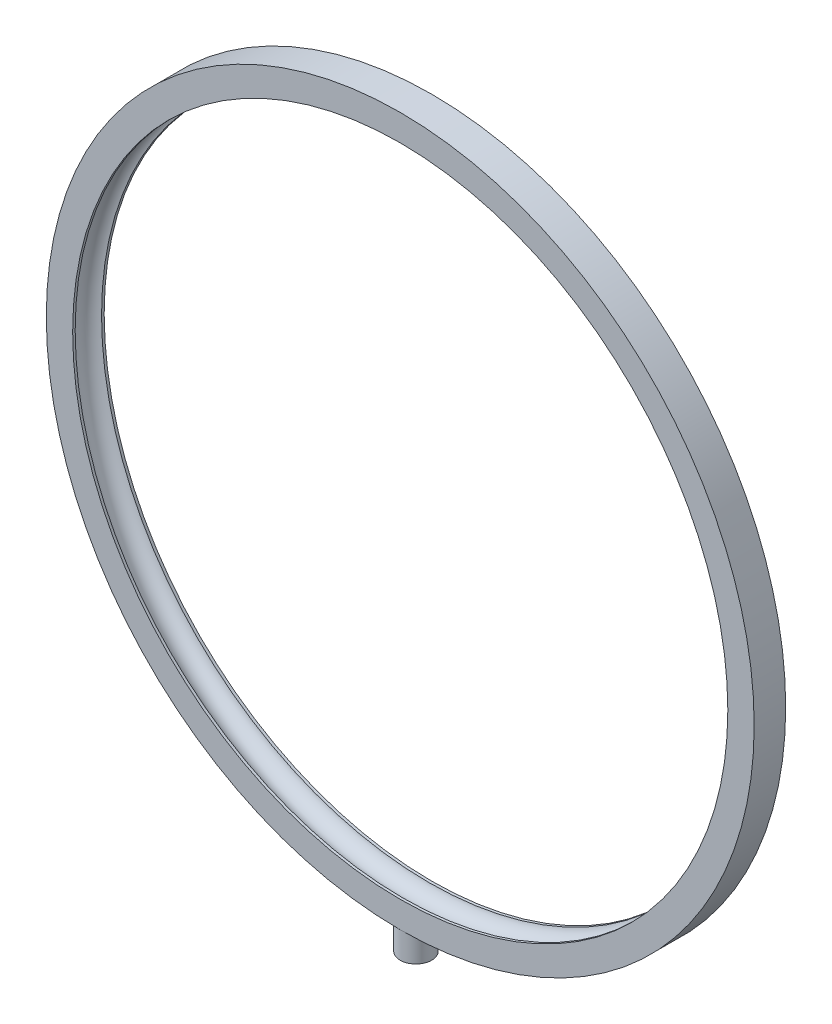
from build123d import *

# Parameters (mm, degrees)
SKETCH3_R           = 5.975
BOSS_EXTRUDE1_DEPTH = 10


with BuildPart() as part:
    # Sketch1 → Revolve1 (revolve)
    with BuildSketch(Plane(origin=(0, 0, 0), x_dir=(0, 0, -1), z_dir=(1, 0, 0))):
        with BuildLine():
            Line((-5.954399753, 124.24716621), (-5.954399753, 134.24716621))
            Line((-5.954399753, 134.24716621), (6, 134.24716621))
            Line((6, 134.24716621), (6, 124.24716621))
            Line((6, 124.24716621), (5, 124.24716621))
            ThreePointArc((5, 124.24716621), (0, 128.24716621), (-5, 124.24716621))
            Line((-5, 124.24716621), (-5.954399753, 124.24716621))
        make_face()
    revolve(axis=Axis((0, 0, 30.30234015), (0, 0, -1)))


with BuildPart() as body_2:
    # Sketch3 → Boss-Extrude1 (new body)
    with BuildSketch(Plane(origin=(0, -134.24716621, 0), x_dir=(-1, 0, 0), z_dir=(0, -1, 0))):
        Circle(SKETCH3_R)
    extrude(amount=BOSS_EXTRUDE1_DEPTH)


solid = Compound([part.part, body_2.part])
